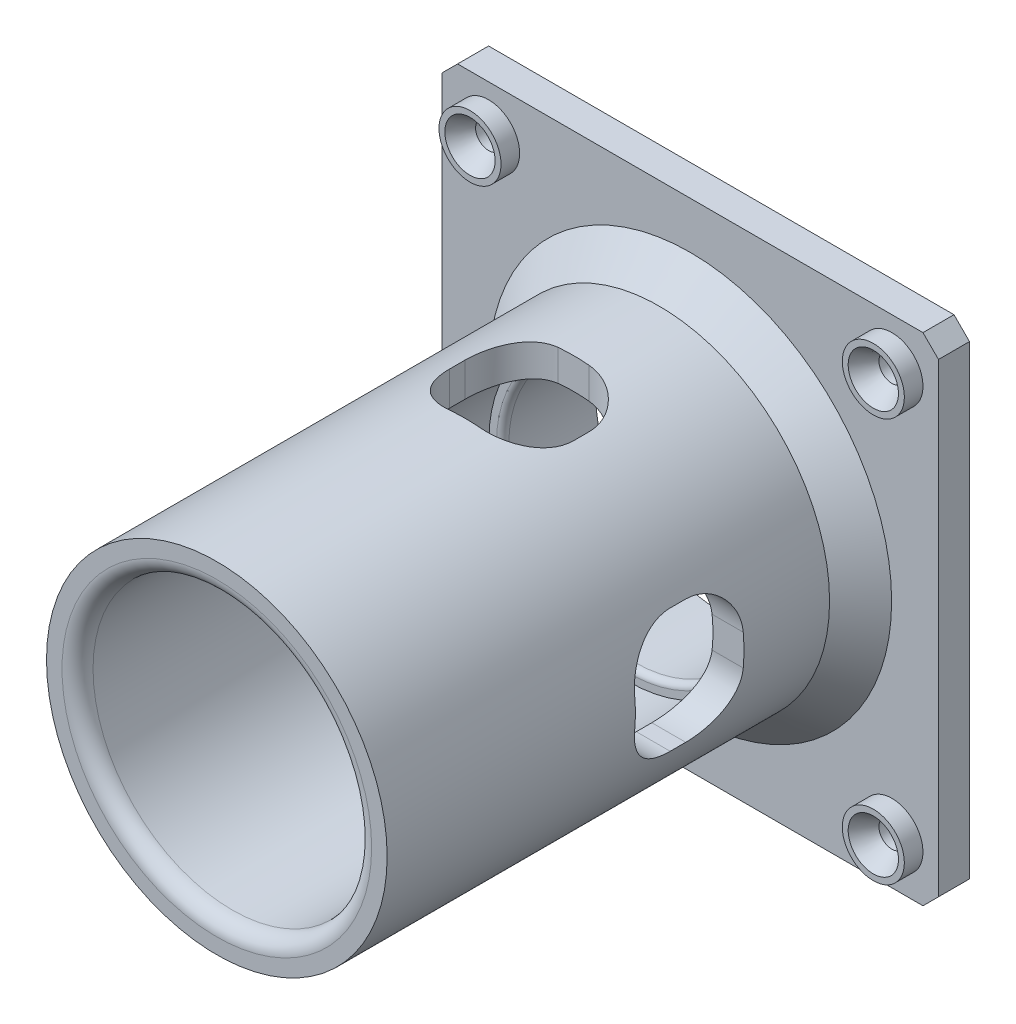
from build123d import *

# Parameters (mm, degrees)
SKETCH1_R                = 27.45
SKETCH1_R_2              = 22.45
BOSS_EXTRUDE1_DEPTH      = 76.3
SKETCH2_W                = 80
SKETCH2_H                = 80
BOSS_EXTRUDE2_DEPTH      = 5
SKETCH3_R                = 5
BOSS_EXTRUDE3_DEPTH      = 3
SKETCH4_R                = 2.1
CUT_EXTRUDE1_DEPTH       = 9
LPATTERN1_COUNT          = 2
LPATTERN1_PITCH          = 65
LPATTERN1_COUNT_DIR2     = 2
LPATTERN1_PITCH_DIR2     = 65
LPATTERN2_COUNT          = 2
LPATTERN2_PITCH          = 65
LPATTERN2_COUNT_DIR2     = 2
LPATTERN2_PITCH_DIR2     = 65
SKETCH8_R                = 20.25
CUT_EXTRUDE2_DEPTH       = 6
SKETCH10_R               = 22.45
SKETCH10_R_2             = 20.25
BOSS_EXTRUDE4_DEPTH      = 10
SKETCH9_W                = 20
SKETCH9_H                = 17.5
CUT_EXTRUDE3_DEPTH       = 40
FILLET1_R                = 7.5
CIRPATTERN1_COUNT        = 4
FILLET1_OF_CIRPATTERN1_R = 7.5
FILLET2_R                = 2.5
CHAMFER1_SIZE            = 5
CHAMFER2_SIZE            = 2.5
FILLET3_R                = 1


with BuildPart() as part:
    # Sketch1 → Boss-Extrude1 (new body)
    with BuildSketch(Plane.XY):
        Circle(SKETCH1_R)
        Circle(SKETCH1_R_2, mode=Mode.SUBTRACT)
    extrude(amount=BOSS_EXTRUDE1_DEPTH)

    # Sketch2 → Boss-Extrude2 (add)
    with BuildSketch(Plane(origin=(0, 0, 0), x_dir=(-1, 0, 0), z_dir=(0, 0, -1))):
        Rectangle(SKETCH2_W, SKETCH2_H)
    extrude(amount=BOSS_EXTRUDE2_DEPTH)

    # Sketch3 → Boss-Extrude3 (add)
    with BuildSketch(Plane.XY):
        with Locations((-32.5, 32.5)):
            Circle(SKETCH3_R)
    boss_extrude3 = extrude(amount=BOSS_EXTRUDE3_DEPTH)

    # Sketch4 → Cut-Extrude1 (cut, through all)
    with BuildSketch(Plane.XY.offset(3)):
        with Locations((-32.5, 32.5)):
            Circle(SKETCH4_R)
        with Locations((32.5, 32.5)):
            Circle(SKETCH4_R)
        with Locations((32.5, -32.5)):
            Circle(SKETCH4_R)
        with Locations((-32.5, -32.5)):
            Circle(SKETCH4_R)
    extrude(amount=-CUT_EXTRUDE1_DEPTH, mode=Mode.SUBTRACT)

    # Sketch7 → Cut-Revolve1 (revolve, cut)
    with BuildSketch(Plane.ZY.offset(32.5)):
        Polygon((3, 32.5), (0, 32.5), (0, 30.4), (3, 28.45), align=None)
    cut_revolve1 = revolve(axis=Axis((-32.5, 32.5, 3), (0, 0, -1)), mode=Mode.SUBTRACT)

    # LPattern1: Boss-Extrude3 2 × 2
    with Locations(*[(i * LPATTERN1_PITCH, -j * LPATTERN1_PITCH_DIR2, 0) for i in range(LPATTERN1_COUNT) for j in range(LPATTERN1_COUNT_DIR2) if (i, j) != (0, 0)]):
        add(boss_extrude3)

    # LPattern2: Cut-Revolve1 2 × 2
    with Locations(*[(i * LPATTERN2_PITCH, -j * LPATTERN2_PITCH_DIR2, 0) for i in range(LPATTERN2_COUNT) for j in range(LPATTERN2_COUNT_DIR2) if (i, j) != (0, 0)]):
        add(cut_revolve1, mode=Mode.SUBTRACT)

    # Sketch8 → Cut-Extrude2 (cut, through all)
    with BuildSketch(Plane.XY):
        Circle(SKETCH8_R)
    extrude(amount=-CUT_EXTRUDE2_DEPTH, mode=Mode.SUBTRACT)

    # Sketch10 → Boss-Extrude4 (add)
    with BuildSketch(Plane.XY):
        Circle(SKETCH10_R)
        Circle(SKETCH10_R_2, mode=Mode.SUBTRACT)
    extrude(amount=BOSS_EXTRUDE4_DEPTH)

    # Sketch9 → Cut-Extrude3 (cut)
    with BuildSketch(Plane.XZ.offset(40)):
        with Locations((0, 27.55)):
            Rectangle(SKETCH9_W, SKETCH9_H)
    cut_extrude3 = extrude(amount=-CUT_EXTRUDE3_DEPTH, mode=Mode.SUBTRACT)

    # Fillet1
    fillet1_edges = [part.edges().sort_by_distance(p)[0] for p in [
        (-10, -22.831754196, 18.8),
        (-10, -22.831754196, 36.3),
        (10, -22.831754196, 36.3),
        (10, -22.831754196, 18.8),
    ]]
    fillet(fillet1_edges, radius=FILLET1_R)

    # CirPattern1: Cut-Extrude3 ×4 about axis
    cirpattern1_axis = Axis((0, 0, 0), (0, 0, 1))
    for i in range(1, CIRPATTERN1_COUNT):
        add(cut_extrude3.rotate(cirpattern1_axis, i * 360 / CIRPATTERN1_COUNT), mode=Mode.SUBTRACT)

    # Fillet1 of CirPattern1
    fillet1_of_cirpattern1_edges = [part.edges().sort_by_distance(p)[0] for p in [
        (22.831754196, -10, 18.8),
        (22.831754196, -10, 36.3),
        (22.831754196, 10, 36.3),
        (22.831754196, 10, 18.8),
        (10, 22.831754196, 18.8),
        (10, 22.831754196, 36.3),
        (-10, 22.831754196, 36.3),
        (-10, 22.831754196, 18.8),
        (-22.831754196, 10, 18.8),
        (-22.831754196, 10, 36.3),
        (-22.831754196, -10, 36.3),
        (-22.831754196, -10, 18.8),
    ]]
    fillet(fillet1_of_cirpattern1_edges, radius=FILLET1_OF_CIRPATTERN1_R)

    # Fillet2
    fillet2_edges = [part.edges().sort_by_distance(p)[0] for p in [
        (-22.45, 0, 76.3),
    ]]
    fillet(fillet2_edges, radius=FILLET2_R)

    # Chamfer1
    chamfer1_edges = [part.edges().sort_by_distance(p)[0] for p in [
        (-27.45, 0, 0),
    ]]
    chamfer(chamfer1_edges, length=CHAMFER1_SIZE)

    # Chamfer2
    chamfer2_edges = [part.edges().sort_by_distance(p)[0] for p in [
        (-40, -40, -2.5),
        (-40, 40, -2.5),
        (40, 40, -2.5),
        (40, -40, -2.5),
    ]]
    chamfer(chamfer2_edges, length=CHAMFER2_SIZE)

    # Fillet3
    fillet3_edges = [part.edges().sort_by_distance(p)[0] for p in [
        (-20.25, 0, 10),
    ]]
    fillet(fillet3_edges, radius=FILLET3_R)


solid = part.part
